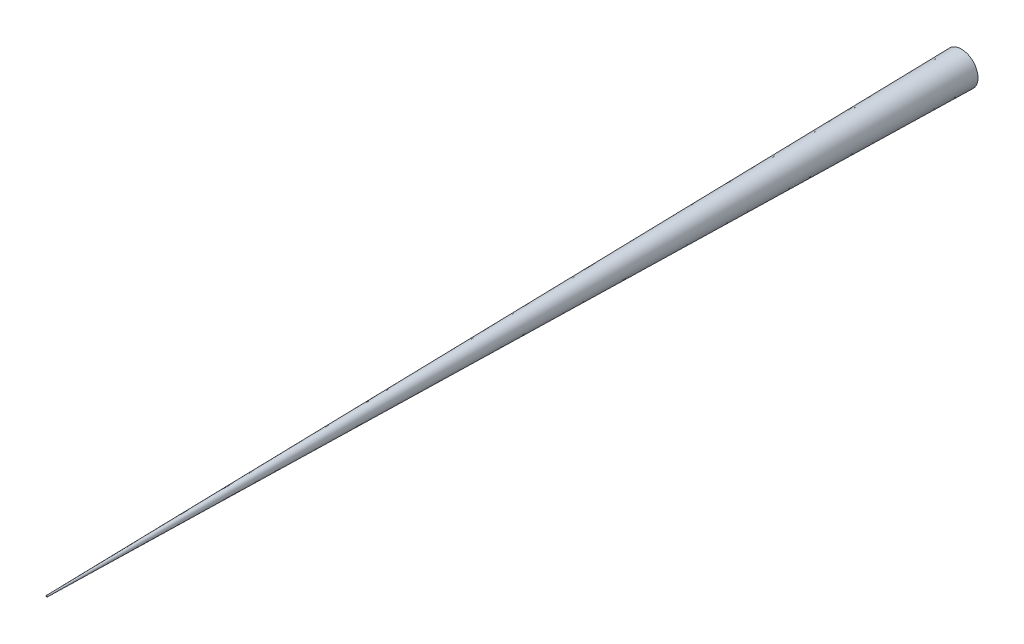
from build123d import *

# Parameters (mm, degrees)
SKETCH1_R           = 12.7
BOSS_EXTRUDE2_DEPTH = 700
BOSS_EXTRUDE2_TAPER = 1


with BuildPart() as part:
    # Sketch1 → Boss-Extrude2 (new body)
    with BuildSketch(Plane.XY):
        Circle(SKETCH1_R)
    extrude(amount=BOSS_EXTRUDE2_DEPTH, taper=BOSS_EXTRUDE2_TAPER)


solid = part.part
